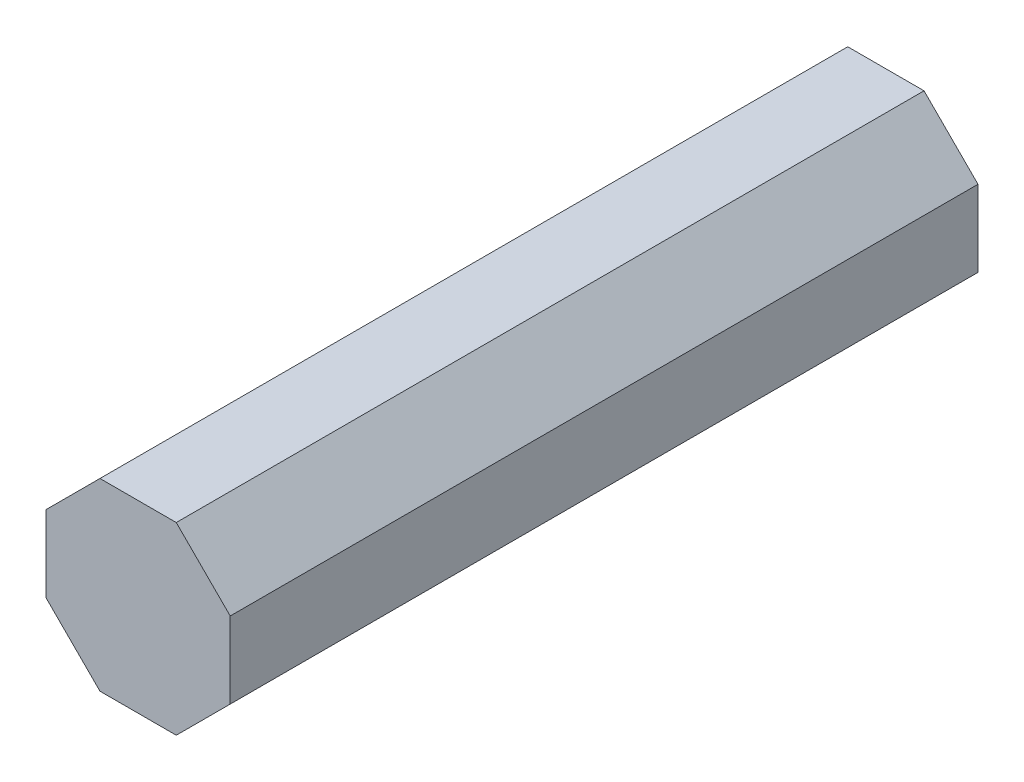
from build123d import *

# Parameters (mm, degrees)
BOSS_EXTRUDE1_DEPTH = 30


with BuildPart() as part:
    # Sketch2 → Boss-Extrude1 (new body)
    with BuildSketch(Plane.XY):
        Polygon((1.530733729, 3.69551813), (-1.530733729, 3.69551813), (-3.69551813, 1.530733729), (-3.69551813, -1.530733729), (-1.530733729, -3.69551813), (1.530733729, -3.69551813), (3.69551813, -1.530733729), (3.69551813, 1.530733729), align=None)
    extrude(amount=BOSS_EXTRUDE1_DEPTH)


solid = part.part
